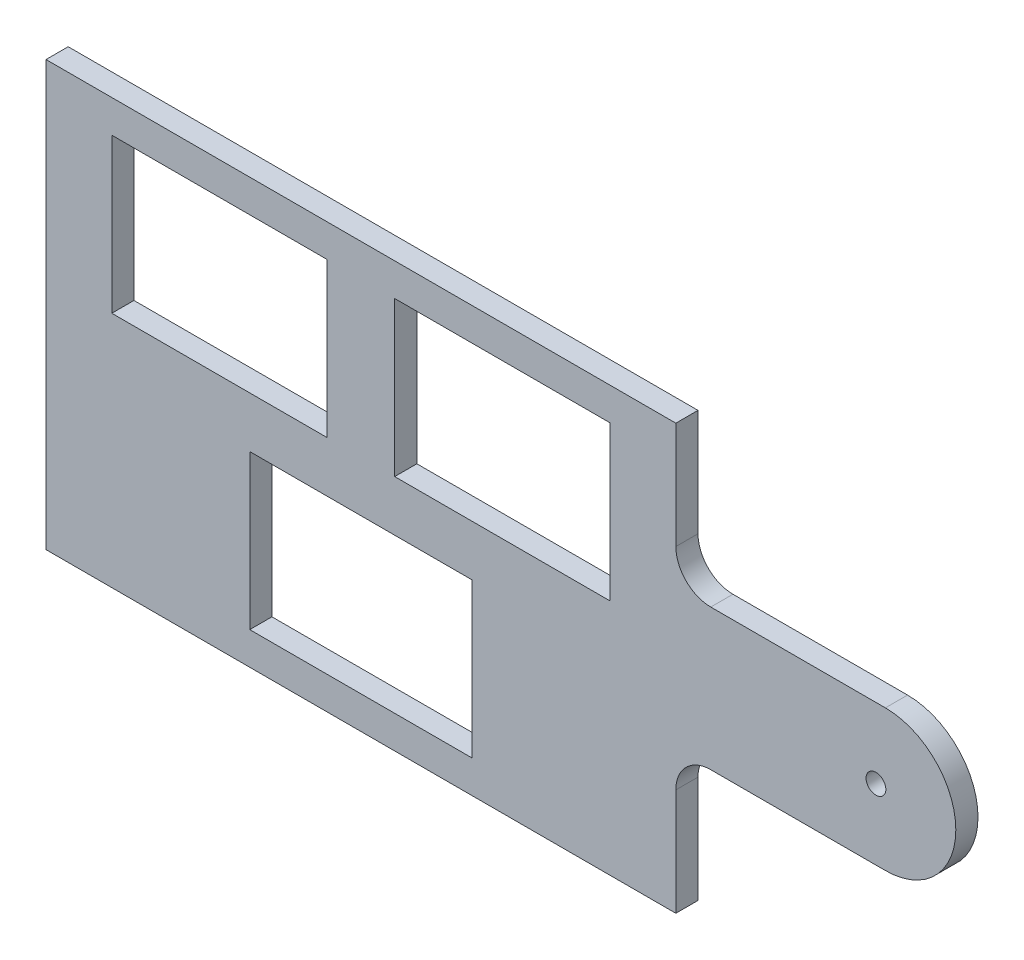
from build123d import *

# Parameters (mm, degrees)
SKETCH1_W           = 90.17
SKETCH1_H           = 60.77
BOSS_EXTRUDE1_DEPTH = 3.175
SKETCH2_W           = 30.83
SKETCH2_H           = 22.08
SKETCH2_W_2         = 31.83
CUT_EXTRUDE1_DEPTH  = 4.175
BOSS_EXTRUDE2_DEPTH = 3.175
FILLET1_R           = 5
SKETCH5_R           = 1.415
CUT_EXTRUDE2_DEPTH  = 10


with BuildPart() as part:
    # Sketch1 → Boss-Extrude1 (new body)
    with BuildSketch(Plane.XY):
        Rectangle(SKETCH1_W, SKETCH1_H)
    extrude(amount=BOSS_EXTRUDE1_DEPTH)

    # Sketch2 → Cut-Extrude1 (cut, through all)
    with BuildSketch(Plane.XY.offset(3.175)):
        with Locations((20.25, 14.675)):
            Rectangle(SKETCH2_W, SKETCH2_H)
        with Locations((-20.25, 14.675)):
            Rectangle(SKETCH2_W, SKETCH2_H)
        with Locations((0, -14.675)):
            Rectangle(SKETCH2_W_2, SKETCH2_H)
    extrude(amount=-CUT_EXTRUDE1_DEPTH, mode=Mode.SUBTRACT)

    # Sketch3 → Boss-Extrude2 (add)
    with BuildSketch(Plane.XY.offset(3.175)):
        with BuildLine():
            Line((45.085, 10.085), (45.085, -10.085))
            Line((45.085, -10.085), (75.085, -10.085))
            ThreePointArc((75.085, -10.085), (85.17, 0), (75.085, 10.085))
            Line((75.085, 10.085), (45.085, 10.085))
        make_face()
    extrude(amount=-BOSS_EXTRUDE2_DEPTH)

    # Fillet1
    fillet1_edges = [part.edges().sort_by_distance(p)[0] for p in [
        (45.085, -10.085, 1.5875),
        (45.085, 10.085, 1.5875),
    ]]
    fillet(fillet1_edges, radius=FILLET1_R)

    # Sketch5 → Cut-Extrude2 (cut)
    with BuildSketch(Plane.XY.offset(3.175)):
        with Locations((73.735, 0)):
            Circle(SKETCH5_R)
    extrude(amount=-CUT_EXTRUDE2_DEPTH, mode=Mode.SUBTRACT)


solid = part.part
